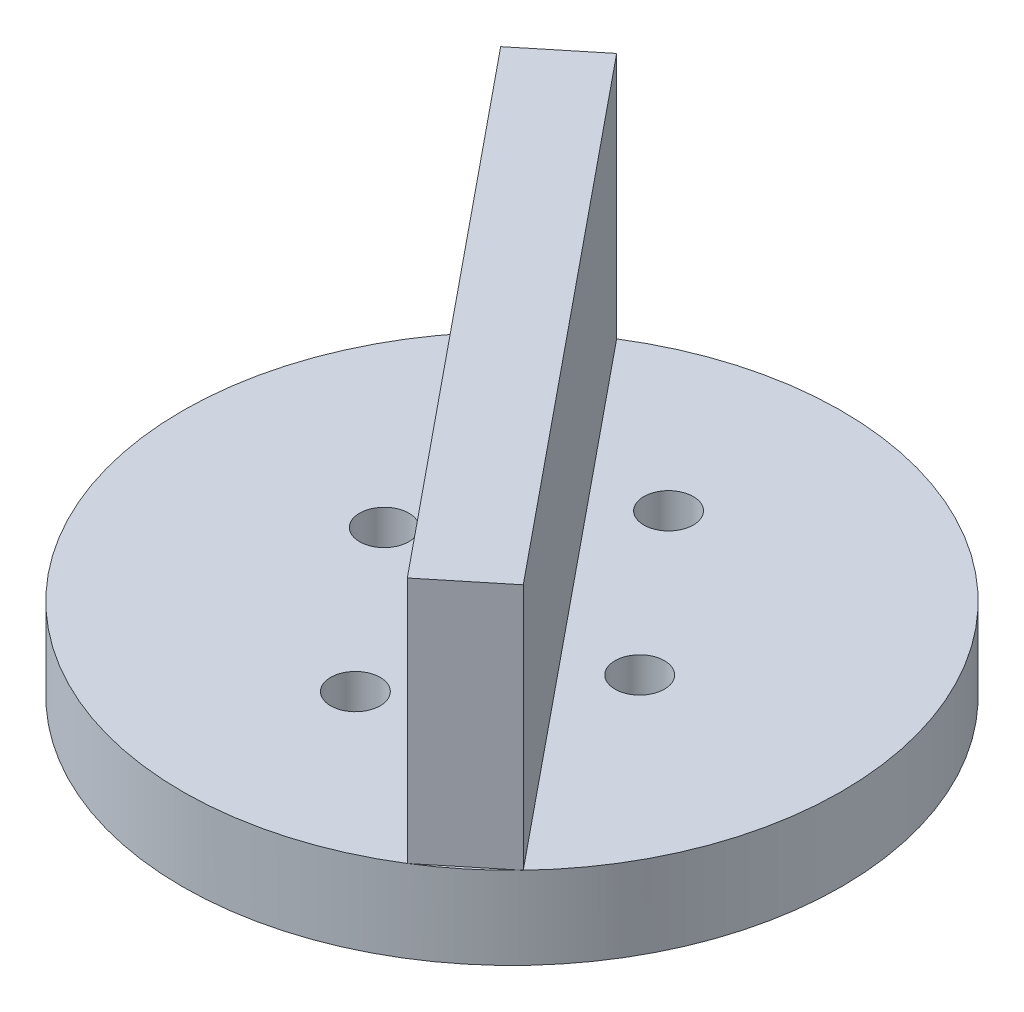
from build123d import *

# Parameters (mm, degrees)
SKETCH1_R           = 20
BOSS_EXTRUDE1_DEPTH = 5
CUT_EXTRUDE1_REACH  = 7
SKETCH2_R           = 1.5
BOSS_EXTRUDE2_DEPTH = 15


with BuildPart() as part:
    # Sketch1 → Boss-Extrude1 (new body)
    with BuildSketch(Plane(origin=(0, 0, 0), x_dir=(1, 0, 0), z_dir=(0, 1, 0))):
        Circle(SKETCH1_R)
    extrude(amount=BOSS_EXTRUDE1_DEPTH)

    # Sketch2 → Cut-Extrude1 (cut, up to next)
    with BuildSketch(Plane(origin=(0, 5, 0), x_dir=(1, 0, 0), z_dir=(0, 1, 0)), mode=Mode.PRIVATE) as cut_extrude1_sk1:
        with Locations((0, 9.5)):
            Circle(SKETCH2_R)
    cut_extrude1_tool1 = extrude(cut_extrude1_sk1.sketch, amount=-CUT_EXTRUDE1_REACH, mode=Mode.PRIVATE) & part.part
    add(cut_extrude1_tool1.solids().sort_by_distance((0, 5, -9.5))[0], mode=Mode.SUBTRACT)
    # Sketch2 → Cut-Extrude1 (cut, up to next)
    with BuildSketch(Plane(origin=(0, 5, 0), x_dir=(1, 0, 0), z_dir=(0, 1, 0)), mode=Mode.PRIVATE) as cut_extrude1_sk2:
        with Locations((0, -9.5)):
            Circle(SKETCH2_R)
    cut_extrude1_tool2 = extrude(cut_extrude1_sk2.sketch, amount=-CUT_EXTRUDE1_REACH, mode=Mode.PRIVATE) & part.part
    add(cut_extrude1_tool2.solids().sort_by_distance((0, 5, 9.5))[0], mode=Mode.SUBTRACT)
    # Sketch2 → Cut-Extrude1 (cut, up to next)
    with BuildSketch(Plane(origin=(0, 5, 0), x_dir=(1, 0, 0), z_dir=(0, 1, 0)), mode=Mode.PRIVATE) as cut_extrude1_sk3:
        with Locations((-7.75, 0)):
            Circle(SKETCH2_R)
    cut_extrude1_tool3 = extrude(cut_extrude1_sk3.sketch, amount=-CUT_EXTRUDE1_REACH, mode=Mode.PRIVATE) & part.part
    add(cut_extrude1_tool3.solids().sort_by_distance((-7.75, 5, 0))[0], mode=Mode.SUBTRACT)
    # Sketch2 → Cut-Extrude1 (cut, up to next)
    with BuildSketch(Plane(origin=(0, 5, 0), x_dir=(1, 0, 0), z_dir=(0, 1, 0)), mode=Mode.PRIVATE) as cut_extrude1_sk4:
        with Locations((7.75, 0)):
            Circle(SKETCH2_R)
    cut_extrude1_tool4 = extrude(cut_extrude1_sk4.sketch, amount=-CUT_EXTRUDE1_REACH, mode=Mode.PRIVATE) & part.part
    add(cut_extrude1_tool4.solids().sort_by_distance((7.75, 5, 0))[0], mode=Mode.SUBTRACT)

    # Sketch3 → Boss-Extrude2 (add)
    with BuildSketch(Plane(origin=(0, 5, 0), x_dir=(1, 0, 0), z_dir=(0, 1, 0))):
        Polygon((-14.480538437, 13.795434266), (10.606213333, -16.956067903), (14.480538437, -13.795434266), (-10.606213333, 16.956067903), align=None)
    extrude(amount=BOSS_EXTRUDE2_DEPTH)


solid = part.part
